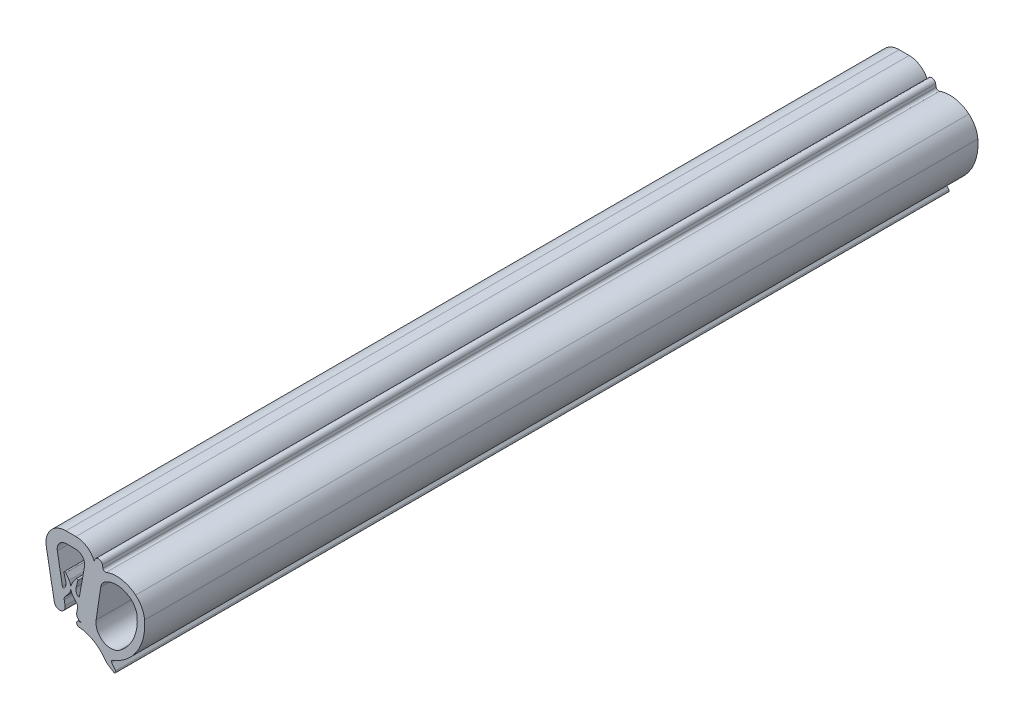
from build123d import *

# Parameters (mm, degrees)
AUFSATZ_LINEAR_AUSTRAGEN1_DEPTH = 167


with BuildPart() as part:
    # Skizze2 → Aufsatz-Linear austragen1 (new body)
    with BuildSketch(Plane.XY):
        with BuildLine():
            Line((2.249463717, -12.202979692), (1.649463717, -12.202979692))
            ThreePointArc((1.649463717, -12.202979692), (1.149883527, -12.682494733), (1.608528118, -13.201302152))
            ThreePointArc((1.608528118, -13.201302152), (4.502520079, -14.096742674), (6.747175365, -16.131079375))
            ThreePointArc((6.747175365, -16.131079375), (7.112932008, -16.556565076), (7.551520932, -16.906501858))
            Line((7.551520932, -16.906501858), (8.535645624, -17.550973384))
            ThreePointArc((8.535645624, -17.550973384), (8.918780894, -17.505267924), (8.94, -17.12))
            Line((8.94, -17.12), (8.16, -16.08))
            ThreePointArc((8.16, -16.08), (8.112111724, -15.815617889), (8.295145631, -15.618920721))
            ThreePointArc((8.295145631, -15.618920721), (13.246952934, -11.602086173), (14.764621506, -5.40918399))
            ThreePointArc((14.764621506, -5.40918399), (14.212742534, -3.511796734), (12.968892358, -1.976386191))
            ThreePointArc((12.968892358, -1.976386191), (10.155247914, -0.685662514), (7.072691879, -0.969230769))
            ThreePointArc((7.072691879, -0.969230769), (6.651398908, -0.933817355), (6.407847641, -0.588238626))
            Line((6.407847641, -0.588238626), (6.312927175, -0.058818198))
            ThreePointArc((6.312927175, -0.058818198), (5.320884778, 0.573394727), (4.771236166, -0.466666667))
            ThreePointArc((4.771236166, -0.466666667), (3.309401077, 1.465986324), (1, 2.2))
            Line((1, 2.2), (-1, 2.2))
            ThreePointArc((-1, 2.2), (-4.071944008, 0.761866509), (-4.934955236, -2.518419995))
            Line((-4.934955236, -2.518419995), (-3.33211269, -11.297565499))
            ThreePointArc((-3.33211269, -11.297565499), (-2.055417632, -12.182653085), (-1.166814744, -10.90840224))
            Line((-1.166814744, -10.90840224), (-1.338225332, -9.939343825))
            ThreePointArc((-1.338225332, -9.939343825), (-1.321388756, -9.586318071), (-1.154086658, -9.274997238))
            Line((-1.154086658, -9.274997238), (-0.493477704, -8.515448887))
            ThreePointArc((-0.493477704, -8.515448887), (-0.004204046, -7.306949206), (-0.36152629, -6.053082782))
            Line((-0.36152629, -6.053082782), (-1.035929659, -5.085628136))
            ThreePointArc((-1.035929659, -5.085628136), (-1.283701743, -5.018357444), (-1.393540989, -5.250417116))
            Line((-1.393540989, -5.250417116), (-1.048442583, -6.575179263))
            ThreePointArc((-1.048442583, -6.575179263), (-1.038559429, -7.2912299), (-1.361771833, -7.930260364))
            ThreePointArc((-1.361771833, -7.930260364), (-1.566325174, -7.992907386), (-1.710478362, -7.834835956))
            Line((-1.710478362, -7.834835956), (-2.722484964, -2.113523607))
            ThreePointArc((-2.722484964, -2.113523607), (-2.329192244, -0.643354526), (-0.95, 0))
            Line((-0.95, 0), (0.95, 0))
            ThreePointArc((0.95, 0), (2.329192244, -0.643354526), (2.722484964, -2.113523607))
            Line((2.722484964, -2.113523607), (1.710478362, -7.834835956))
            ThreePointArc((1.710478362, -7.834835956), (1.566325174, -7.992907386), (1.361771833, -7.930260364))
            ThreePointArc((1.361771833, -7.930260364), (1.038559429, -7.2912299), (1.048442583, -6.575179263))
            Line((1.048442583, -6.575179263), (1.393540989, -5.250417116))
            ThreePointArc((1.393540989, -5.250417116), (1.283701743, -5.018357444), (1.035929659, -5.085628136))
            Line((1.035929659, -5.085628136), (0.36152629, -6.053082782))
            ThreePointArc((0.36152629, -6.053082782), (0.004204046, -7.306949206), (0.493477704, -8.515448887))
            Line((0.493477704, -8.515448887), (1.154086658, -9.274997238))
            ThreePointArc((1.154086658, -9.274997238), (1.321388756, -9.586318071), (1.338225332, -9.939343825))
            Line((1.338225332, -9.939343825), (1.166286689, -10.911387565))
            ThreePointArc((1.166286689, -10.911387565), (1.406630414, -11.809817401), (2.249463717, -12.202979692))
        make_face()
        with BuildLine():
            Line((5.966676435, -4.111321151), (5.046108567, -10.269930006))
            ThreePointArc((5.046108567, -10.269930006), (6.451136103, -13.2747072), (9.765769631, -13.148244023))
            ThreePointArc((9.765769631, -13.148244023), (12.521328986, -9.803634295), (13.26992828, -5.535248103))
            ThreePointArc((13.26992828, -5.535248103), (12.883613, -4.207077023), (12.012917876, -3.132289643))
            ThreePointArc((12.012917876, -3.132289643), (9.572349016, -2.120338399), (6.984465825, -2.652581079))
            ThreePointArc((6.984465825, -2.652581079), (6.304480495, -3.262578078), (5.966676435, -4.111321151))
        make_face(mode=Mode.SUBTRACT)
    extrude(amount=AUFSATZ_LINEAR_AUSTRAGEN1_DEPTH)


solid = part.part
